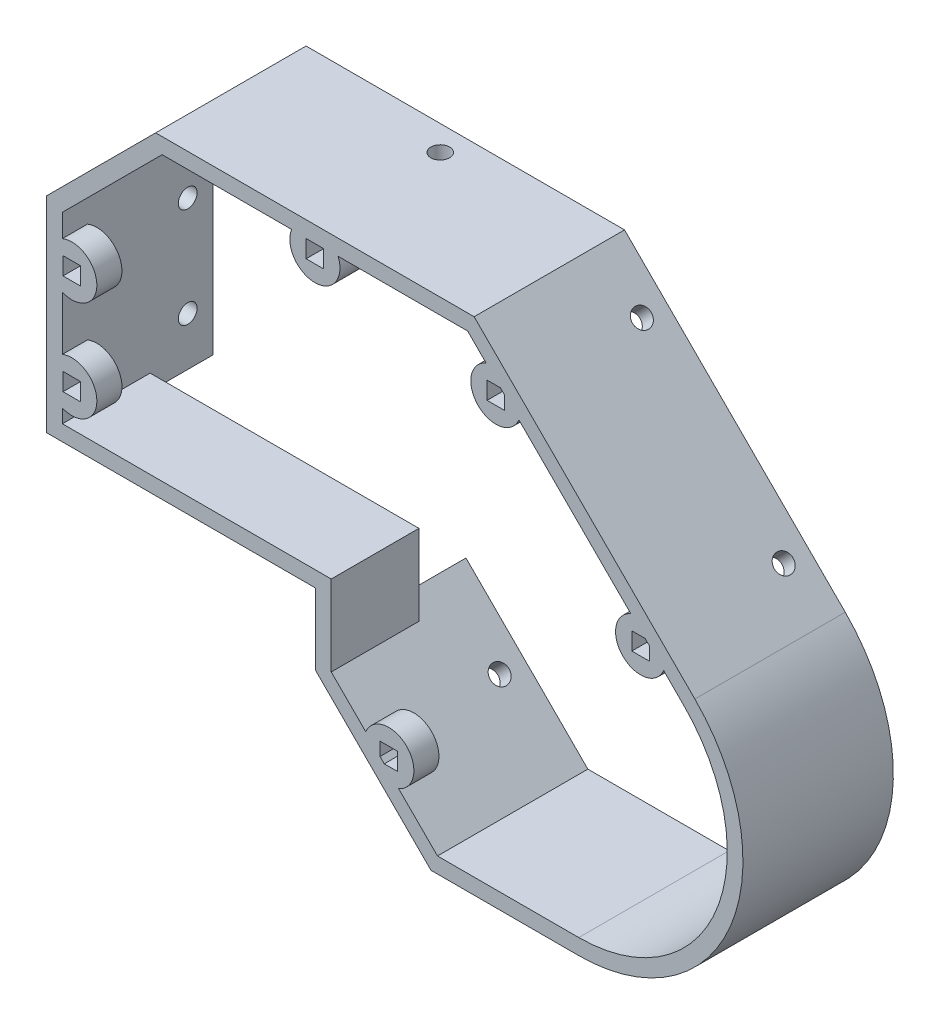
from build123d import *

# Parameters (mm, degrees)
RESSALTO_EXTRUS_O1_DEPTH = 48
ESBO_O12_R               = 1.5
CORTE_EXTRUS_O10_DEPTH   = 10
ESBO_O13_R               = 1.5
CORTE_EXTRUS_O11_DEPTH   = 10
ESBO_O14_R               = 1.5
CORTE_EXTRUS_O12_DEPTH   = 10
ESBO_O15_R               = 1.5
CORTE_EXTRUS_O13_DEPTH   = 10
CORTE_EXTRUS_O14_DEPTH   = 10
CORTE_EXTRUS_O15_DEPTH   = 24
ESBO_O17_R               = 4
ESBO_O17_W               = 2.8
ESBO_O17_H               = 2.8
RESSALTO_EXTRUS_O2_DEPTH = 4
CORTE_EXTRUS_O16_DEPTH   = 24


with BuildPart() as part:
    # Model → Ressalto-extrusão1 (new body)
    with BuildSketch(Plane.XY):
        with BuildLine():
            Line((-0.7, 0), (39, 0))
            Line((39, 0), (39.7, 0))
            Line((39.7, 0), (39.7, -11.380317396))
            Line((39.7, -11.380317396), (50.182424304, -21.8627417))
            Line((50.182424304, -21.8627417), (58.119682605, -29.8))
            Line((58.119682605, -29.8), (81.7, -29.8))
            ThreePointArc((81.7, -29.8), (105.905643752, -13.626305928), (100.226197667, 14.926197667))
            Line((100.226197667, 14.926197667), (65.00338056, 50.149014774))
            Line((65.00338056, 50.149014774), (50.111140335, 50.149014774))
            Line((50.111140335, 50.149014774), (14.181595121, 50.149014774))
            Line((14.181595121, 50.149014774), (-3.2, 32.767419653))
            Line((-3.2, 32.767419653), (-3.2, 5))
            Line((-3.2, 5), (-3.2, 0))
            Line((-3.2, 0), (-0.7, 0))
        make_face()
        with BuildLine():
            Line((-0.7, 2.5), (39, 2.5))
            Line((39, 2.5), (39.7, 2.5))
            Line((39.7, 2.5), (42.2, 2.5))
            Line((42.2, 2.5), (42.2, -10.34478349))
            Line((42.2, -10.34478349), (51.950191257, -20.094974747))
            Line((51.950191257, -20.094974747), (59.15521651, -27.3))
            Line((59.15521651, -27.3), (81.7, -27.3))
            ThreePointArc((81.7, -27.3), (103.595944921, -12.669597347), (98.458430714, 13.158430714))
            Line((98.458430714, 13.158430714), (63.967846654, 47.649014774))
            Line((63.967846654, 47.649014774), (50.111140335, 47.649014774))
            Line((50.111140335, 47.649014774), (15.217129027, 47.649014774))
            Line((15.217129027, 47.649014774), (-0.7, 31.731885747))
            Line((-0.7, 31.731885747), (-0.7, 2.5))
        make_face(mode=Mode.SUBTRACT)
    extrude(amount=RESSALTO_EXTRUS_O1_DEPTH)

    # Esboço12 → Corte-extrusão10 (cut)
    with BuildSketch(Plane(origin=(57.576197667, 57.576197667, 0), x_dir=(0, 0, -1), z_dir=(0.707106781, 0.707106781, 0))):
        with Locations((-44, -20.072657306)):
            Circle(ESBO_O12_R)
        with Locations((-44, -52.072657306)):
            Circle(ESBO_O12_R)
    extrude(amount=-CORTE_EXTRUS_O10_DEPTH, mode=Mode.SUBTRACT)

    # Esboço13 → Corte-extrusão11 (cut)
    with BuildSketch(Plane(origin=(0, 50.149014774, 0), x_dir=(1, 0, 0), z_dir=(0, 1, 0))):
        with Locations((39.59248784, -44)):
            Circle(ESBO_O13_R)
    extrude(amount=-CORTE_EXTRUS_O11_DEPTH, mode=Mode.SUBTRACT)

    # Esboço14 → Corte-extrusão12 (cut)
    with BuildSketch(Plane.ZY.offset(3.2)):
        with Locations((44, 23.701037279)):
            Circle(ESBO_O14_R)
        with Locations((44, 7.740898975)):
            Circle(ESBO_O14_R)
    extrude(amount=-CORTE_EXTRUS_O12_DEPTH, mode=Mode.SUBTRACT)

    # Esboço15 → Corte-extrusão13 (cut)
    with BuildSketch(Plane(origin=(14.159841302, 14.159841302, 0), x_dir=(0, 0, 1), z_dir=(-0.707106781, -0.707106781, 0))):
        with Locations((44, -46.881179593)):
            Circle(ESBO_O15_R)
    extrude(amount=-CORTE_EXTRUS_O13_DEPTH, mode=Mode.SUBTRACT)

    # Esboço16 → Corte-extrusão14 (cut)
    with BuildSketch(Plane.XY.offset(48)):
        Polygon((39.7, 0), (39.7, -7.84478349), (42.2, -10.34478349), (42.2, 2.5), (-0.7, 2.5), (-0.7, 0), align=None)
    extrude(amount=-CORTE_EXTRUS_O14_DEPTH, mode=Mode.SUBTRACT)

    # Esboço18 → Corte-extrusão15 (cut)
    with BuildSketch(Plane(origin=(0, 0, 0), x_dir=(-1, 0, 0), z_dir=(0, 0, -1))):
        with BuildLine():
            Line((-39.7, 0), (3.2, 0))
            Line((3.2, 0), (3.2, 32.767419653))
            Line((3.2, 32.767419653), (-14.181595121, 50.149014774))
            Line((-14.181595121, 50.149014774), (-65.00338056, 50.149014774))
            Line((-65.00338056, 50.149014774), (-100.226197667, 14.926197667))
            ThreePointArc((-100.226197667, 14.926197667), (-105.905643752, -13.626305928), (-81.7, -29.8))
            Line((-81.7, -29.8), (-58.119682605, -29.8))
            Line((-58.119682605, -29.8), (-39.7, -11.380317396))
            Line((-39.7, -11.380317396), (-39.7, 0))
        make_face()
    extrude(amount=-CORTE_EXTRUS_O15_DEPTH, mode=Mode.SUBTRACT)

    # Esboço17 → Ressalto-extrusão2 (add)
    with BuildSketch(Plane(origin=(0, 0, 24), x_dir=(-1, 0, 0), z_dir=(0, 0, -1))):
        with Locations((-91.568699638, 17.926841447)):
            Circle(ESBO_O17_R)
        with Locations((-91.568699638, 17.926841447)):
            Rectangle(ESBO_O17_W, ESBO_O17_H, mode=Mode.SUBTRACT)
        with Locations((-68.47265349, 41.022887595)):
            Circle(ESBO_O17_R)
        with Locations((-68.47265349, 41.022887595)):
            Rectangle(ESBO_O17_W, ESBO_O17_H, mode=Mode.SUBTRACT)
        with Locations((-39.59248784, 46.149014774)):
            Circle(ESBO_O17_R)
        with Locations((-39.59248784, 46.149014774)):
            Rectangle(ESBO_O17_W, ESBO_O17_H, mode=Mode.SUBTRACT)
        with Locations((-0.8, 24.383709827)):
            Circle(ESBO_O17_R)
        with Locations((-0.8, 24.383709827)):
            Rectangle(ESBO_O17_W, ESBO_O17_H, mode=Mode.SUBTRACT)
        with Locations((-0.8, 8.383709827)):
            Circle(ESBO_O17_R)
        with Locations((-0.8, 8.383709827)):
            Rectangle(ESBO_O17_W, ESBO_O17_H, mode=Mode.SUBTRACT)
        with Locations((-51.388268427, -17.411731573)):
            Circle(ESBO_O17_R)
        with Locations((-51.388268427, -17.411731573)):
            Rectangle(ESBO_O17_W, ESBO_O17_H, mode=Mode.SUBTRACT)
    extrude(amount=-RESSALTO_EXTRUS_O2_DEPTH)


with BuildPart() as body_2:
    # Espelhar2: mirrored copy
    add(part.part.mirror(Plane(origin=(81.7, -3.6, 48), x_dir=(1, 0, 0), z_dir=(0, 0, 1))))


with BuildPart() as part_1:
    add(part.part)

    # Esboço19 → Corte-extrusão16 (cut)
    with BuildSketch(Plane(origin=(0, 0, 24), x_dir=(-1, 0, 0), z_dir=(0, 0, -1))):
        with BuildLine():
            Line((-58.119682605, -29.8), (-39.7, -11.380317396))
            Line((-39.7, -11.380317396), (-39.7, 0))
            Line((-39.7, 0), (3.2, 0))
            Line((3.2, 0), (3.2, 32.767419653))
            Line((3.2, 32.767419653), (-14.181595121, 50.149014774))
            Line((-14.181595121, 50.149014774), (-65.00338056, 50.149014774))
            Line((-65.00338056, 50.149014774), (-100.226197667, 14.926197667))
            ThreePointArc((-100.226197667, 14.926197667), (-105.905643752, -13.626305928), (-81.7, -29.8))
            Line((-81.7, -29.8), (-58.119682605, -29.8))
        make_face()
    extrude(amount=-CORTE_EXTRUS_O16_DEPTH, mode=Mode.SUBTRACT)


solid = body_2.part
